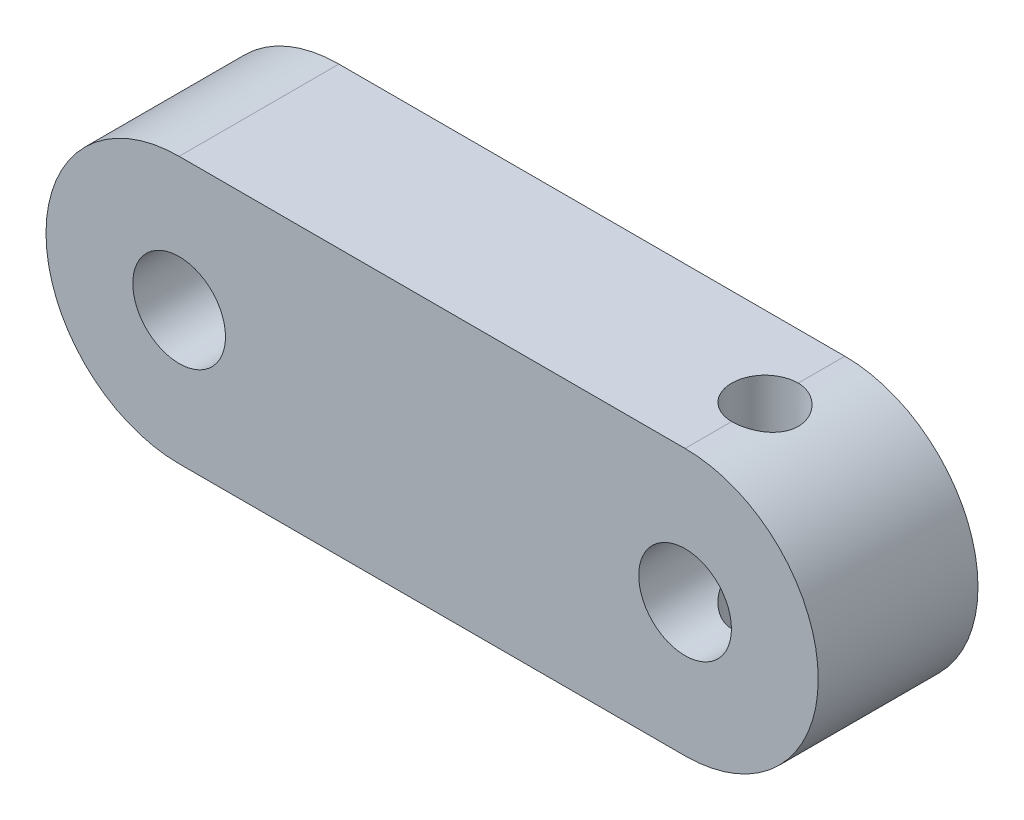
from build123d import *

# Parameters (mm, degrees)
SKETCH1_R           = 5
SKETCH1_R_2         = 1.740677898
BOSS_EXTRUDE1_DEPTH = 6
SKETCH2_R           = 1.25
CUT_EXTRUDE1_DEPTH  = 11


with BuildPart() as part:
    # Sketch1 → Boss-Extrude1 (new body)
    with BuildSketch(Plane.XY):
        with Locations((-35.04245283, -0.806603774)):
            Circle(SKETCH1_R)
        with Locations((-35.04245283, -0.806603774)):
            Circle(SKETCH1_R_2, mode=Mode.SUBTRACT)
        with BuildLine():
            Line((-16.04245283, 4.193396226), (-35.04245283, 4.193396226))
            ThreePointArc((-35.04245283, 4.193396226), (-31.506918924, 2.728930132), (-30.04245283, -0.806603774))
            ThreePointArc((-30.04245283, -0.806603774), (-31.506918924, -4.34213768), (-35.04245283, -5.806603774))
            Line((-35.04245283, -5.806603774), (-16.04245283, -5.806603774))
            ThreePointArc((-16.04245283, -5.806603774), (-21.04245283, -0.806603774), (-16.04245283, 4.193396226))
        make_face()
        with Locations((-16.04245283, -0.806603774)):
            Circle(SKETCH1_R)
        with Locations((-16.04245283, -0.806603774)):
            Circle(SKETCH1_R_2, mode=Mode.SUBTRACT)
    extrude(amount=BOSS_EXTRUDE1_DEPTH)

    # Sketch2 → Cut-Extrude1 (cut, through all)
    with BuildSketch(Plane(origin=(0, 4.193396226, 0), x_dir=(1, 0, 0), z_dir=(0, 1, 0))):
        with Locations((-16.04245283, -3)):
            Circle(SKETCH2_R)
    extrude(amount=-CUT_EXTRUDE1_DEPTH, mode=Mode.SUBTRACT)


solid = part.part
